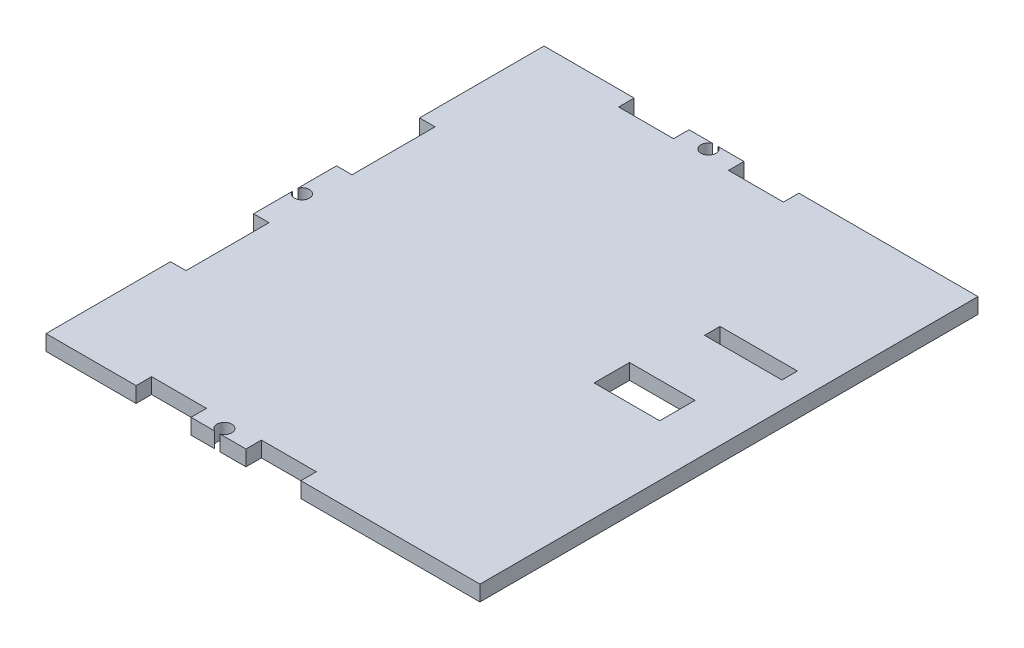
from build123d import *

# Parameters (mm, degrees)
SKETCH1_W           = 66.85
SKETCH1_H           = 96.52
BOSS_EXTRUDE2_DEPTH = 3
SKETCH2_W           = 31.925
SKETCH2_H           = 3
CUT_EXTRUDE1_DEPTH  = 3
SKETCH3_W           = 48.26
SKETCH3_H           = 3
CUT_EXTRUDE2_DEPTH  = 3
SKETCH4_W           = 10.643333334
SKETCH4_H           = 3
BOSS_EXTRUDE3_DEPTH = 3
SKETCH5_W           = 16.086666666
SKETCH5_H           = 3
BOSS_EXTRUDE4_DEPTH = 3
SKETCH6_R           = 1.45
CUT_EXTRUDE10_DEPTH = 3
SKETCH7_R           = 1.45
CUT_EXTRUDE11_DEPTH = 3
SKETCH9_W           = 96.52
SKETCH9_H           = 3
BOSS_EXTRUDE5_DEPTH = 17.25
SKETCH10_W          = 12.7
SKETCH10_H          = 6.86
CUT_EXTRUDE12_DEPTH = 3
SKETCH12_W          = 15
SKETCH12_H          = 3
CUT_EXTRUDE14_DEPTH = 3


with BuildPart() as part:
    # Sketch1 → Boss-Extrude2 (new body)
    with BuildSketch(Plane(origin=(0, 0, 0), x_dir=(1, 0, 0), z_dir=(0, 1, 0))):
        Rectangle(SKETCH1_W, SKETCH1_H)
    extrude(amount=BOSS_EXTRUDE2_DEPTH)

    # Sketch2 → Cut-Extrude1 (cut)
    with BuildSketch(Plane.XY.offset(48.26)):
        with Locations((0, 1.5)):
            Rectangle(SKETCH2_W, SKETCH2_H)
    cut_extrude1 = extrude(amount=-CUT_EXTRUDE1_DEPTH, mode=Mode.SUBTRACT)

    # Mirror1: Cut-Extrude1 across plane
    add(cut_extrude1.mirror(Plane.XY), mode=Mode.SUBTRACT)

    # Sketch3 → Cut-Extrude2 (cut)
    with BuildSketch(Plane.ZY.offset(33.425)):
        with Locations((0, 1.5)):
            Rectangle(SKETCH3_W, SKETCH3_H)
    extrude(amount=-CUT_EXTRUDE2_DEPTH, mode=Mode.SUBTRACT)

    # Sketch4 → Boss-Extrude3 (add)
    with BuildSketch(Plane.XY.offset(45.26)):
        with Locations((0, 1.5)):
            Rectangle(SKETCH4_W, SKETCH4_H)
    boss_extrude3 = extrude(amount=BOSS_EXTRUDE3_DEPTH)

    # Mirror2: Boss-Extrude3 across plane
    add(boss_extrude3.mirror(Plane.XY))

    # Sketch5 → Boss-Extrude4 (add)
    with BuildSketch(Plane.ZY.offset(30.425)):
        with Locations((0, 1.5)):
            Rectangle(SKETCH5_W, SKETCH5_H)
    extrude(amount=BOSS_EXTRUDE4_DEPTH)

    # Sketch6 → Cut-Extrude10 (cut)
    with BuildSketch(Plane(origin=(0, 3, 0), x_dir=(1, 0, 0), z_dir=(0, 1, 0))):
        with Locations((-32.075, 0)):
            Circle(SKETCH6_R)
    extrude(amount=-CUT_EXTRUDE10_DEPTH, mode=Mode.SUBTRACT)

    # Sketch7 → Cut-Extrude11 (cut)
    with BuildSketch(Plane(origin=(0, 3, 0), x_dir=(1, 0, 0), z_dir=(0, 1, 0))):
        with Locations((-0.211991592, -46.91)):
            Circle(SKETCH7_R)
    cut_extrude11 = extrude(amount=-CUT_EXTRUDE11_DEPTH, mode=Mode.SUBTRACT)

    # Mirror3: Cut-Extrude11 across plane
    add(cut_extrude11.mirror(Plane.XY), mode=Mode.SUBTRACT)

    # Sketch9 → Boss-Extrude5 (add)
    with BuildSketch(Plane(origin=(33.425, 0, 0), x_dir=(0, 0, -1), z_dir=(1, 0, 0))):
        with Locations((0, 1.5)):
            Rectangle(SKETCH9_W, SKETCH9_H)
    extrude(amount=BOSS_EXTRUDE5_DEPTH)

    # Sketch10 → Cut-Extrude12 (cut)
    with BuildSketch(Plane.XZ):
        with Locations((34.325, 0)):
            Rectangle(SKETCH10_W, SKETCH10_H)
    extrude(amount=-CUT_EXTRUDE12_DEPTH, mode=Mode.SUBTRACT)

    # Sketch12 → Cut-Extrude14 (cut)
    with BuildSketch(Plane.XZ):
        with Locations((38.175, -16.76)):
            Rectangle(SKETCH12_W, SKETCH12_H)
    extrude(amount=-CUT_EXTRUDE14_DEPTH, mode=Mode.SUBTRACT)


solid = part.part
